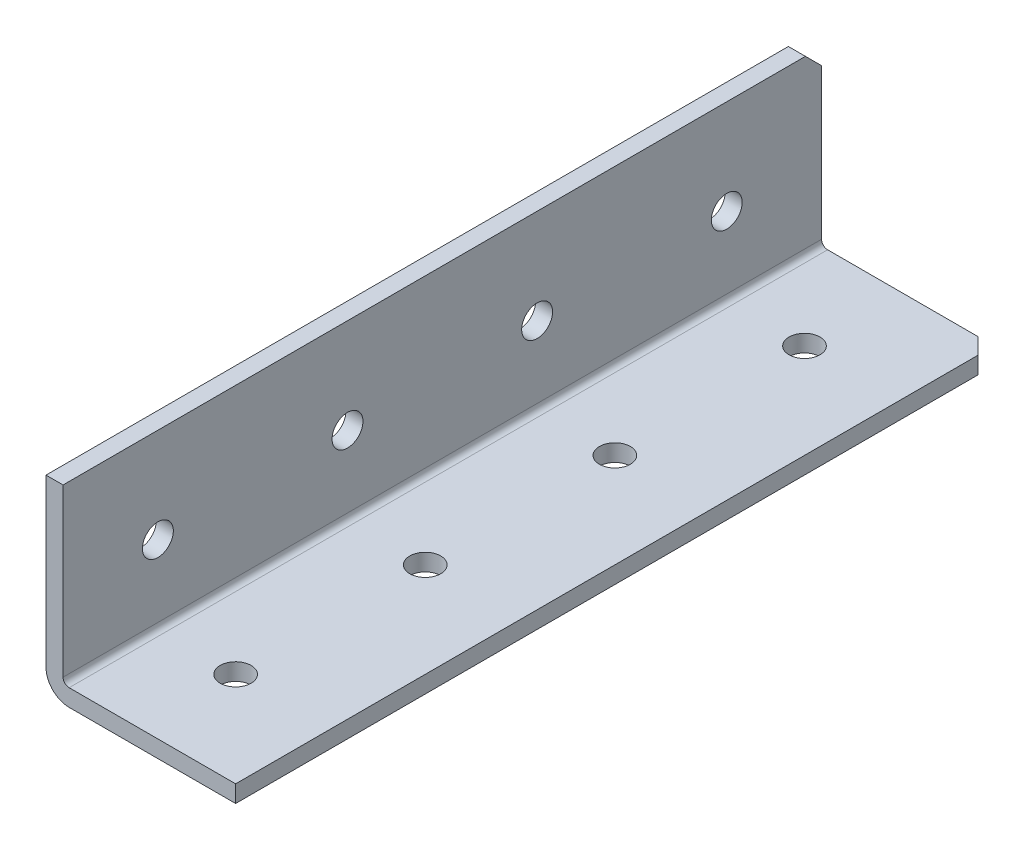
from build123d import *

# Parameters (mm, degrees)
SKETCH1_W                  = 25.4
SKETCH1_H                  = 1498.6
BOSS_EXTRUDE1_DEPTH        = 25.4
SKETCH2_W                  = 23.114
SKETCH2_H                  = 23.114
CUT_EXTRUDE1_DEPTH         = 1499.6
M3_5_CLEARANCE_HOLE1_D     = 4.1402
M3_5_CLEARANCE_HOLE1_DEPTH = 25.4
M3_5_CLEARANCE_HOLE2_D     = 4.1402
M3_5_CLEARANCE_HOLE2_DEPTH = 25.4
CHAMFER1_SIZE              = 2.159
FILLET1_R                  = 0.8128
FILLET2_R                  = 3.0988
SKETCH8_W                  = 95.882963774
SKETCH8_H                  = 79.338329604
CUT_EXTRUDE3_DEPTH         = 1397


with BuildPart() as part:
    # Sketch1 → Boss-Extrude1 (new body)
    with BuildSketch(Plane(origin=(0, 0, 0), x_dir=(0, -1, 0), z_dir=(-1, 0, 0))):
        with Locations((-12.7, 0)):
            Rectangle(SKETCH1_W, SKETCH1_H)
    extrude(amount=-BOSS_EXTRUDE1_DEPTH)

    # Sketch2 → Cut-Extrude1 (cut, through all)
    with BuildSketch(Plane(origin=(0, 0, -749.3), x_dir=(-1, 0, 0), z_dir=(0, 0, -1))):
        with Locations((-13.843, 13.843)):
            Rectangle(SKETCH2_W, SKETCH2_H)
    extrude(amount=-CUT_EXTRUDE1_DEPTH, mode=Mode.SUBTRACT)

    # M3.5 Clearance Hole1
    with Locations(Plane(origin=(0, 0, 0), x_dir=(-1, 0, 0), z_dir=(0, -1, 0))):
        with Locations((-12.7, 736.6), (-12.7, 711.2), (-12.7, 685.8), (-12.7, 660.4), (-12.7, 635), (-12.7, 609.6), (-12.7, 584.2), (-12.7, 558.8), (-12.7, 533.4), (-12.7, 508), (-12.7, 482.6), (-12.7, 457.2), (-12.7, 431.8), (-12.7, 406.4), (-12.7, 381), (-12.7, 355.6), (-12.7, 330.2), (-12.7, 304.8), (-12.7, 279.4), (-12.7, 254), (-12.7, 228.6), (-12.7, 203.2), (-12.7, 177.8), (-12.7, 152.4), (-12.7, 127), (-12.7, 101.6), (-12.7, 76.2), (-12.7, 50.8), (-12.7, 25.4), (-12.7, 0), (-12.7, -25.4), (-12.7, -50.8), (-12.7, -76.2), (-12.7, -101.6), (-12.7, -127), (-12.7, -152.4), (-12.7, -177.8), (-12.7, -203.2), (-12.7, -228.6), (-12.7, -254), (-12.7, -279.4), (-12.7, -304.8), (-12.7, -330.2), (-12.7, -355.6), (-12.7, -381), (-12.7, -406.4), (-12.7, -431.8), (-12.7, -457.2), (-12.7, -482.6), (-12.7, -508), (-12.7, -533.4), (-12.7, -558.8), (-12.7, -584.2), (-12.7, -609.6), (-12.7, -635), (-12.7, -660.4), (-12.7, -685.8), (-12.7, -711.2), (-12.7, -736.6)):
            Hole(M3_5_CLEARANCE_HOLE1_D / 2, depth=M3_5_CLEARANCE_HOLE1_DEPTH)

    # M3.5 Clearance Hole2
    with Locations(Plane.ZY):
        with Locations((711.2, 12.7), (736.6, 12.7), (685.8, 12.7), (660.4, 12.7), (635, 12.7), (609.6, 12.7), (584.2, 12.7), (558.8, 12.7), (533.4, 12.7), (508, 12.7), (482.6, 12.7), (457.2, 12.7), (431.8, 12.7), (406.4, 12.7), (381, 12.7), (355.6, 12.7), (330.2, 12.7), (304.8, 12.7), (279.4, 12.7), (254, 12.7), (228.6, 12.7), (203.2, 12.7), (177.8, 12.7), (152.4, 12.7), (127, 12.7), (101.6, 12.7), (76.2, 12.7), (50.8, 12.7), (25.4, 12.7), (0, 12.7), (-25.4, 12.7), (-50.8, 12.7), (-76.2, 12.7), (-101.6, 12.7), (-127, 12.7), (-152.4, 12.7), (-177.8, 12.7), (-203.2, 12.7), (-228.6, 12.7), (-254, 12.7), (-279.4, 12.7), (-304.8, 12.7), (-330.2, 12.7), (-355.6, 12.7), (-381, 12.7), (-406.4, 12.7), (-431.8, 12.7), (-457.2, 12.7), (-482.6, 12.7), (-508, 12.7), (-533.4, 12.7), (-558.8, 12.7), (-584.2, 12.7), (-609.6, 12.7), (-635, 12.7), (-660.4, 12.7), (-685.8, 12.7), (-711.2, 12.7), (-736.6, 12.7)):
            Hole(M3_5_CLEARANCE_HOLE2_D / 2, depth=M3_5_CLEARANCE_HOLE2_DEPTH)

    # Chamfer1
    chamfer1_edges = [part.edges().sort_by_distance(p)[0] for p in [
        (25.4, 1.143, -749.3),
        (1.143, 25.4, 749.3),
        (1.143, 25.4, -749.3),
        (25.4, 1.143, 749.3),
    ]]
    chamfer(chamfer1_edges, length=CHAMFER1_SIZE)

    # Fillet1
    fillet1_edges = [part.edges().sort_by_distance(p)[0] for p in [
        (2.286, 2.286, 0),
    ]]
    fillet(fillet1_edges, radius=FILLET1_R)

    # Fillet2
    fillet2_edges = [part.edges().sort_by_distance(p)[0] for p in [
        (0, 0, 0),
    ]]
    fillet(fillet2_edges, radius=FILLET2_R)

    # Sketch8 → Cut-Extrude3 (cut)
    with BuildSketch(Plane.XY.offset(749.3)):
        with Locations((2.286, 3.0988)):
            Rectangle(SKETCH8_W, SKETCH8_H)
    extrude(amount=-CUT_EXTRUDE3_DEPTH, mode=Mode.SUBTRACT)


solid = part.part
